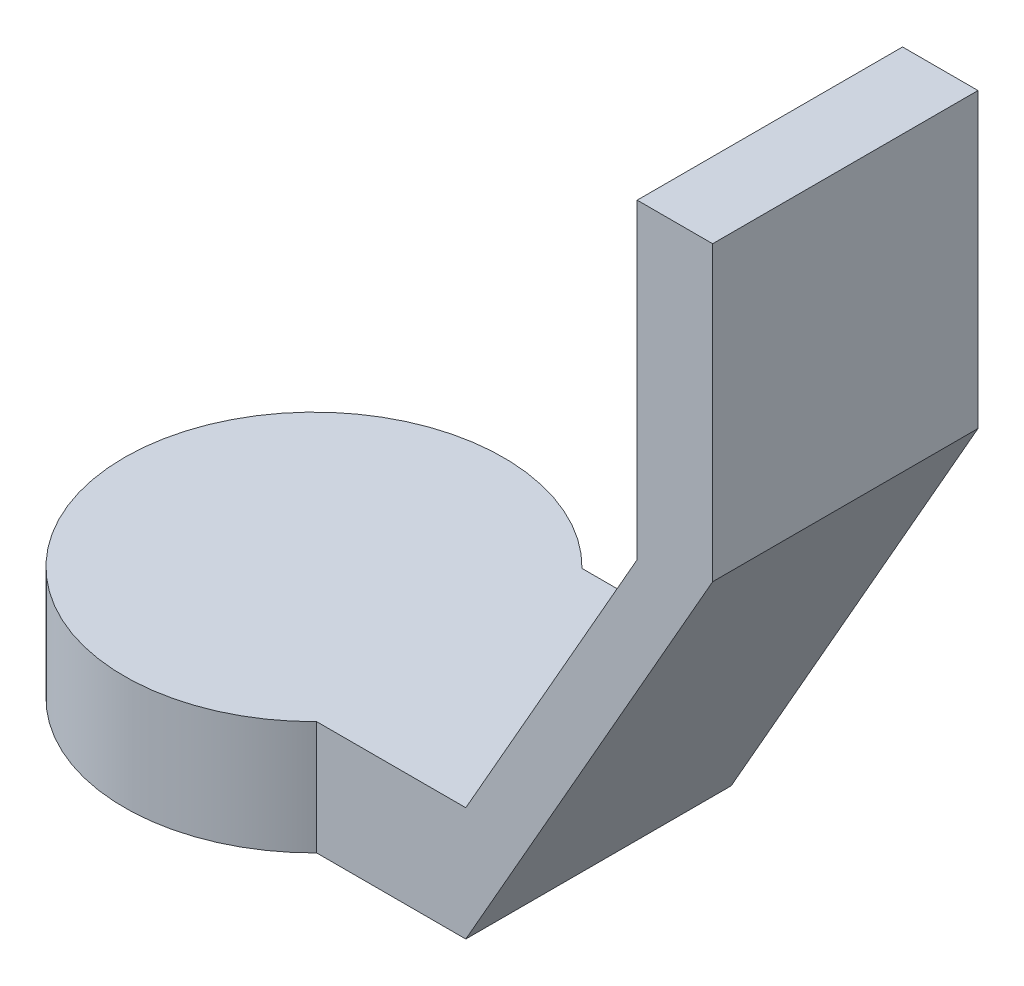
from build123d import *

# Parameters (mm, degrees)
EXTRUDE_1_DEPTH = 30
EXTRUDE_2_DEPTH = 70


with BuildPart() as part:
    # 草图1 → 凸台-拉伸1 (new body)
    with BuildSketch(Plane(origin=(0, 0, 0), x_dir=(1, 0, 0), z_dir=(0, 1, 0))):
        with BuildLine():
            Line((75.055476805, 35), (35.707142143, 35))
            ThreePointArc((35.707142143, 35), (46.289075964, 18.902948088), (50, 0))
            ThreePointArc((50, 0), (46.289075964, -18.902948088), (35.707142143, -35))
            Line((35.707142143, -35), (75.055476805, -35))
            Line((75.055476805, -35), (75.055476805, 35))
        make_face()
        with BuildLine():
            Line((0.055476805, -35), (0.055476805, 35))
            Line((0.055476805, 35), (35.707142143, 35))
            ThreePointArc((35.707142143, 35), (-50, 0), (35.707142143, -35))
            Line((35.707142143, -35), (0.055476805, -35))
        make_face()
        with BuildLine():
            Line((35.707142143, 35), (0.055476805, 35))
            Line((0.055476805, 35), (0.055476805, -35))
            Line((0.055476805, -35), (35.707142143, -35))
            ThreePointArc((35.707142143, -35), (46.289075964, -18.902948088), (50, 0))
            ThreePointArc((50, 0), (46.289075964, 18.902948088), (35.707142143, 35))
        make_face()
    extrude(amount=EXTRUDE_1_DEPTH)

    # 草图2 → 凸台-拉伸2 (add)
    with BuildSketch(Plane.XY.offset(35)):
        Polygon((75.055476805, 0), (140.174133177, 114.192122372), (140.174133177, 191.411564081), (120.26890055, 191.411564081), (120.26890055, 109.286292207), (75.055476805, 30), align=None)
    extrude(amount=-EXTRUDE_2_DEPTH)


solid = part.part
